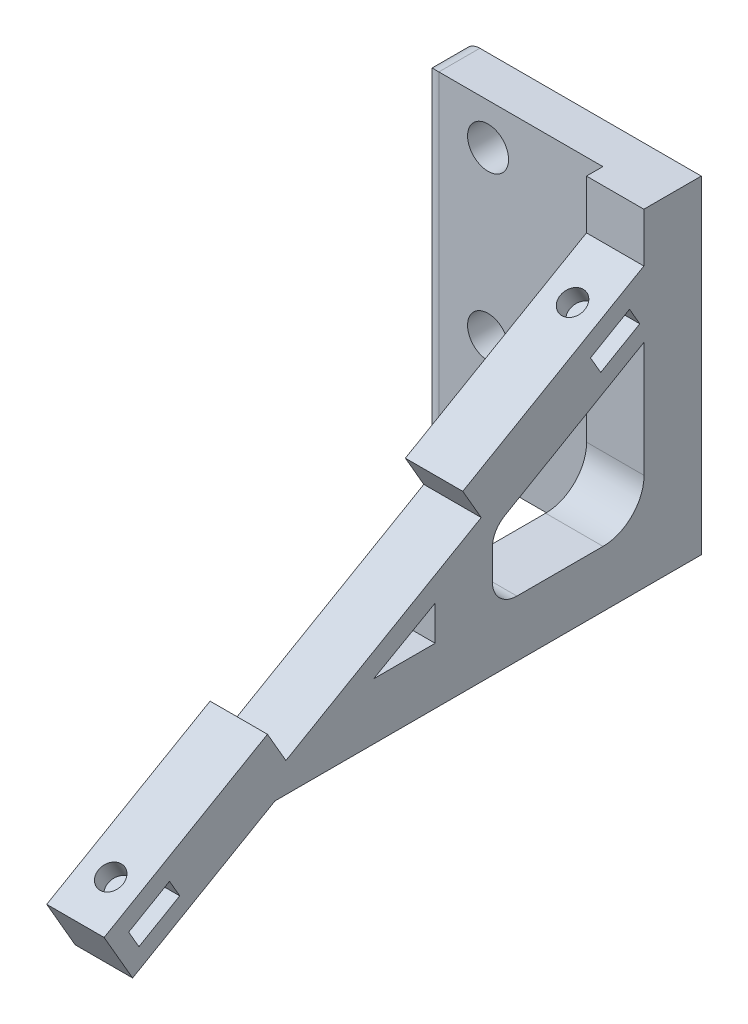
from build123d import *

# Parameters (mm, degrees)
BOSS_EXTRUDE1_DEPTH = 7000
SKETCH8_W           = 29000
SKETCH8_H           = 40000
SKETCH8_R           = 2500
BOSS_EXTRUDE3_DEPTH = 5000
FILLET1_R           = 2000
SKETCH9_R           = 1500
CUT_EXTRUDE1_DEPTH  = 7500


with BuildPart() as part:
    # Sketch1 → Boss-Extrude1 (new body)
    with BuildSketch(Plane(origin=(0, 0, 0), x_dir=(0, 0, -1), z_dir=(1, 0, 0))):
        Polygon((-71013.995318758, 7265.898072848), (-90932.579605801, -4234.101927152), (-87458.303118855, -10251.725322083), (-70107.270427744, -234.101927152), (-18114.648918183, -234.101927152), (-18114.648918183, 39765.898072848), (-25114.648918183, 39765.898072848), (-25114.648918183, 33765.898072848), (-47198.296714686, 21015.898072848), (-44948.296714686, 17118.783755818), (-68763.995318758, 3368.783755818), align=None)
        Polygon((-86690.784266902, -7328.011455498), (-87940.784266902, -5162.947946037), (-82961.138195142, -2287.947946037), (-81711.138195142, -4453.011455498), align=None, mode=Mode.SUBTRACT)
        Polygon((-50564.411297588, 6650.031696168), (-58064.411297588, 6650.031696168), (-50564.411297588, 10900.031696168), align=None, mode=Mode.SUBTRACT)
        with BuildLine():
            Line((-42094.842589731, 15873.015861461), (-25094.842589731, 25713.319742243))
            Line((-25094.842589731, 25713.319742243), (-25094.842589731, 11650.031696168))
            ThreePointArc((-25094.842589731, 11650.031696168), (-26559.308683798, 8114.497790235), (-30094.842589731, 6650.031696168))
            Line((-30094.842589731, 6650.031696168), (-40594.842589731, 6650.031696168))
            ThreePointArc((-40594.842589731, 6650.031696168), (-42716.16293329, 7528.711352608), (-43594.842589731, 9650.031696168))
            Line((-43594.842589731, 9650.031696168), (-43594.842589731, 13271.583512645))
            ThreePointArc((-43594.842589731, 13271.583512645), (-43192.9789446, 14773.036997228), (-42094.842589731, 15873.015861461))
        make_face(mode=Mode.SUBTRACT)
        Polygon((-30374.7121835, 25159.479548575), (-31627.131141319, 27323.144669173), (-26867.067876003, 30078.466376377), (-25614.648918183, 27914.801255779), align=None, mode=Mode.SUBTRACT)
    extrude(amount=-BOSS_EXTRUDE1_DEPTH)

    # Sketch8 → Boss-Extrude3 (add)
    with BuildSketch(Plane(origin=(0, 0, 18114.648918183), x_dir=(-1, 0, 0), z_dir=(0, 0, -1))):
        with Locations((14500, 19765.898072848)):
            Rectangle(SKETCH8_W, SKETCH8_H)
        with Locations((21000, 14765.898072848)):
            Circle(SKETCH8_R, mode=Mode.SUBTRACT)
        with Locations((21000, 34765.898072848)):
            Circle(SKETCH8_R, mode=Mode.SUBTRACT)
    extrude(amount=-BOSS_EXTRUDE3_DEPTH)

    # Fillet1
    fillet1_edges = [part.edges().sort_by_distance(p)[0] for p in [
        (-29000, -234.101927152, 20614.648918183),
        (-29000, 19765.898072848, 23114.648918183),
        (-29000, 39765.898072848, 20614.648918183),
    ]]
    fillet(fillet1_edges, radius=FILLET1_R)

    # Sketch9 → Cut-Extrude1 (cut)
    with BuildSketch(Plane(origin=(0, 36199.385539773, 20899.724985887), x_dir=(1, 0, 0), z_dir=(0, 0.866025404, 0.5))):
        with Locations((-3500, -10868.821249998)):
            Circle(SKETCH9_R)
        with Locations((-3500, -75902.875745792)):
            Circle(SKETCH9_R)
    extrude(amount=-CUT_EXTRUDE1_DEPTH, mode=Mode.SUBTRACT)


solid = part.part
